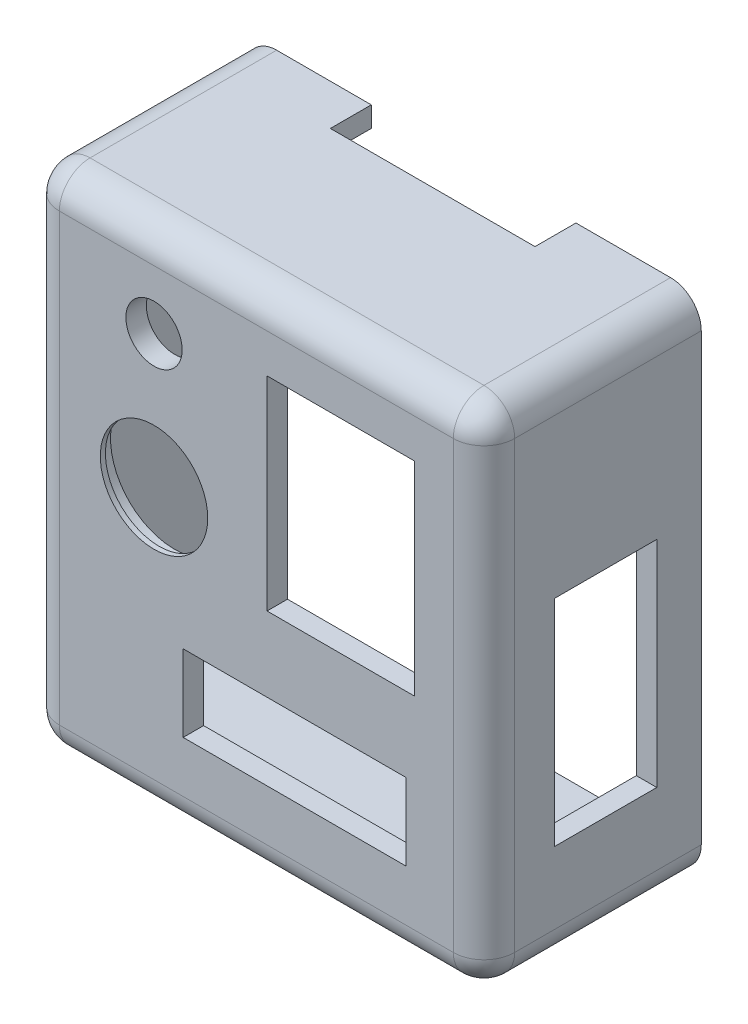
from build123d import *

# Parameters (mm, degrees)
SKETCH1_W           = 128.5875
SKETCH1_H           = 144.4625
BOSS_EXTRUDE1_DEPTH = 61.07176
SHELL1_T            = 6.35
SKETCH2_R           = 8.73125
SKETCH2_R_2         = 19.84375
SKETCH2_W           = 45.72
SKETCH2_H           = 63.1825
SKETCH2_W_2         = 69.215
SKETCH2_H_2         = 23.8125
CUT_EXTRUDE1_DEPTH  = 126.344509202
SKETCH3_W           = 31.75
SKETCH3_H           = 66.675
CUT_EXTRUDE2_DEPTH  = 6.35
SKETCH4_R           = 19.84375
SKETCH4_R_2         = 16.66875
BOSS_EXTRUDE2_DEPTH = 1.5875
SKETCH5_W           = 63.5
SKETCH5_H           = 12.7
CUT_EXTRUDE3_DEPTH  = 6.35
FILLET1_R           = 9.525
FILLET2_R           = 3.175


with BuildPart() as part:
    # Sketch1 → Boss-Extrude1 (new body)
    with BuildSketch(Plane.XY):
        Rectangle(SKETCH1_W, SKETCH1_H)
    extrude(amount=-BOSS_EXTRUDE1_DEPTH)

    # Shell1
    shell1_openings = [part.faces().sort_by_distance(p)[0] for p in [
        (0, 0, -61.07176),
    ]]
    offset(amount=SHELL1_T, openings=shell1_openings, kind=Kind.INTERSECTION)

    # Sketch2 → Cut-Extrude1 (cut, through all)
    with BuildSketch(Plane.XY.offset(6.35)):
        with Locations((-31.75, 50.8)):
            Circle(SKETCH2_R)
        with Locations((-31.75, 9.525)):
            Circle(SKETCH2_R_2)
        with Locations((26.19375, 25.4)):
            Rectangle(SKETCH2_W, SKETCH2_H)
        with Locations((11.90625, -41.275)):
            Rectangle(SKETCH2_W_2, SKETCH2_H_2)
    extrude(amount=-CUT_EXTRUDE1_DEPTH, mode=Mode.SUBTRACT)

    # Sketch3 → Cut-Extrude2 (cut)
    with BuildSketch(Plane(origin=(70.64375, 0, 0), x_dir=(0, 0, -1), z_dir=(1, 0, 0))):
        with Locations((31.39694, -13.43025)):
            Rectangle(SKETCH3_W, SKETCH3_H)
    extrude(amount=-CUT_EXTRUDE2_DEPTH, mode=Mode.SUBTRACT)

    # Sketch4 → Boss-Extrude2 (add)
    with BuildSketch(Plane.XY.offset(6.35)):
        with Locations((-31.75, 9.525)):
            Circle(SKETCH4_R)
        with Locations((-31.75, 9.525)):
            Circle(SKETCH4_R_2, mode=Mode.SUBTRACT)
    extrude(amount=-BOSS_EXTRUDE2_DEPTH)

    # Sketch5 → Cut-Extrude3 (cut)
    with BuildSketch(Plane(origin=(0, 78.58125, 0), x_dir=(1, 0, 0), z_dir=(0, 1, 0))):
        with Locations((0, 54.72176)):
            Rectangle(SKETCH5_W, SKETCH5_H)
    extrude(amount=-CUT_EXTRUDE3_DEPTH, mode=Mode.SUBTRACT)

    # Fillet1
    fillet1_edges = [part.edges().sort_by_distance(p)[0] for p in [
        (0, -78.58125, 6.35),
        (70.64375, 0, 6.35),
        (0, 78.58125, 6.35),
        (-70.64375, 0, 6.35),
        (-70.64375, -78.58125, -27.36088),
        (70.64375, -78.58125, -27.36088),
        (70.64375, 78.58125, -27.36088),
        (-70.64375, 78.58125, -27.36088),
    ]]
    fillet(fillet1_edges, radius=FILLET1_R)

    # Fillet2
    fillet2_edges = [part.edges().sort_by_distance(p)[0] for p in [
        (-64.29375, 0, 0),
        (-64.29375, -72.23125, -30.53588),
        (0, 72.23125, 0),
        (-64.29375, 72.23125, -30.53588),
        (64.29375, 72.23125, -30.53588),
        (64.29375, -72.23125, -30.53588),
        (0, -72.23125, 0),
        (64.29375, 0, 0),
    ]]
    fillet(fillet2_edges, radius=FILLET2_R)


solid = part.part
